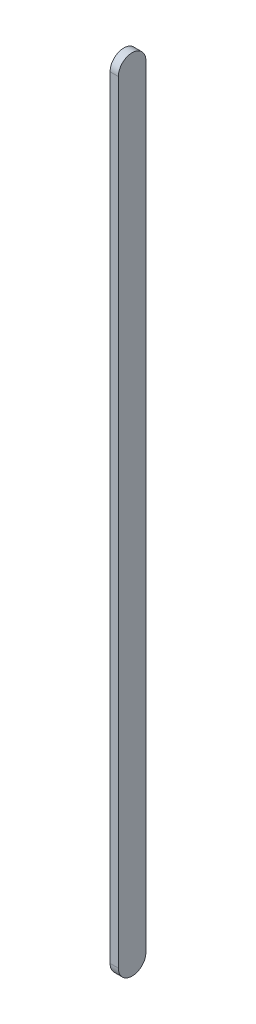
from build123d import *

# Parameters (mm, degrees)
BOSS_EXTRUDE1_DEPTH = 3


with BuildPart() as part:
    # Sketch1 → Boss-Extrude1 (new body)
    with BuildSketch(Plane(origin=(0, 0, 0), x_dir=(0, 0, -1), z_dir=(1, 0, 0))):
        with BuildLine():
            Line((5, 0), (5, -280))
            ThreePointArc((5, -280), (0, -285), (-5, -280))
            Line((-5, -280), (-5, 0))
            ThreePointArc((-5, 0), (0, 5), (5, 0))
        make_face()
    extrude(amount=BOSS_EXTRUDE1_DEPTH)


solid = part.part
